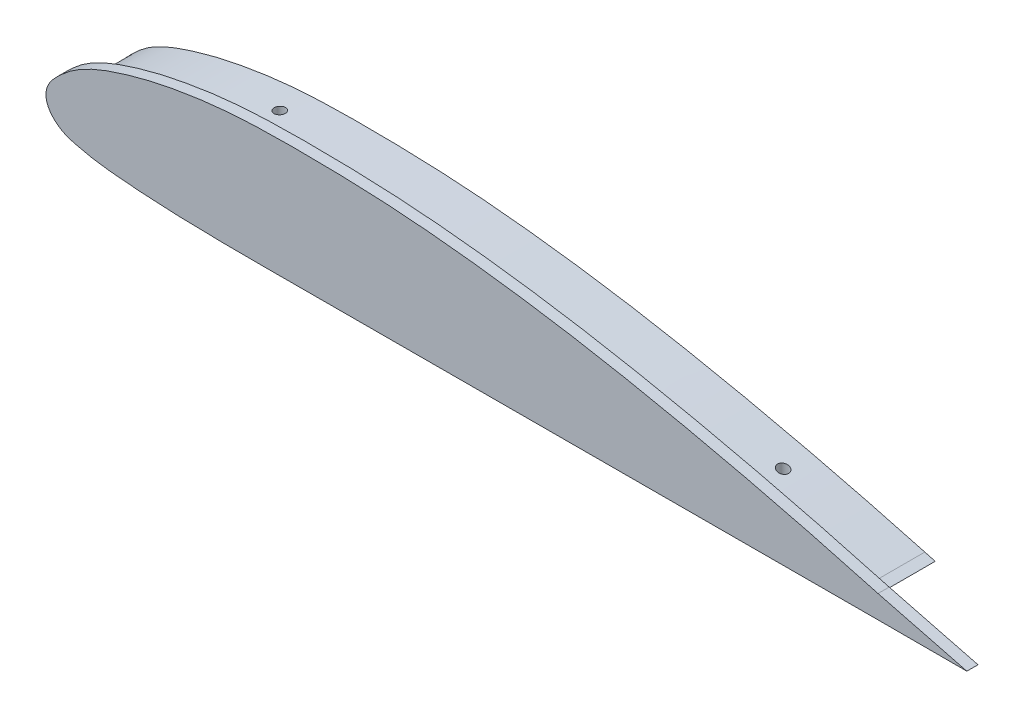
from build123d import *

# Parameters (mm, degrees)
BOSS_EXTRUDE1_DEPTH = 2
BOSS_EXTRUDE2_DEPTH = 10
SKETCH5_R           = 1
CUT_EXTRUDE1_DEPTH  = 36.779701738
CUT_EXTRUDE2_DEPTH  = 10


with BuildPart() as part:
    # Sketch1 → Boss-Extrude1 (new body)
    with BuildSketch(Plane.XY):
        with BuildLine():
            Line((-17.71228779, -35.575775075), (-1.223783329, -35.575775075))
            Line((-1.223783329, -35.575775075), (-17.180879623, -31.471027744))
            add(Edge.make_bspline(
                [(-17.180879623, -31.471027744), (-20.205601063, -30.641326221), (-26.253542154, -28.987884931), (-38.429053109, -25.8814615), (-53.732549887, -22.35224182), (-72.246941298, -18.747840877), (-87.841555491, -16.525613317), (-100.385741413, -15.297530048), (-109.848619286, -14.732094345), (-119.294599062, -14.543032016), (-127.178320958, -14.56973262), (-133.539223008, -14.903304234), (-138.316711816, -15.384960118), (-143.052256856, -16.102664967), (-146.974276822, -16.888033103), (-150.097568386, -17.661404713), (-152.420429022, -18.322368996), (-154.721034301, -19.055449549), (-157.028277155, -19.901839278), (-158.938274428, -20.750408796), (-160.444884569, -21.55195455), (-161.566657514, -22.242769671), (-162.643932605, -23.019791562), (-163.650195181, -23.881188916), (-164.383575737, -24.558119651), (-165.025928384, -25.197908158), (-165.520248718, -25.756694424), (-166.01404091, -26.440083904), (-166.389529061, -27.174457782), (-166.606560914, -27.962527196), (-166.659336808, -28.649852251), (-166.591247193, -29.291839365), (-166.3998375, -29.929741557), (-166.173442593, -30.404271636), (-165.821410784, -30.981688892), (-165.334747379, -31.561760653), (-164.720612919, -32.122103636), (-164.034637493, -32.61453888), (-163.289346674, -33.008452563), (-162.335975169, -33.387772412), (-161.22390742, -33.682088018), (-160.104439348, -33.942204217), (-158.883960635, -34.21330953), (-157.657113746, -34.434015389), (-156.022342218, -34.670136087), (-154.015300198, -34.873778442), (-151.668906344, -35.07398473), (-148.50365767, -35.312261934), (-144.559314611, -35.521168431), (-139.829186921, -35.675419619), (-135.108692198, -35.753722312), (-130.396839566, -35.782270868), (-125.692032249, -35.778984727), (-119.431159104, -35.756330318), (-111.611698629, -35.742482847), (-102.219561445, -35.729658954), (-92.83016126, -35.711302455), (-83.440388902, -35.694221978), (-70.920821592, -35.6710383), (-55.271517114, -35.643697918), (-36.492093713, -35.609371091), (-23.972198663, -35.587692749), (-17.71228779, -35.575775075)],
                knots=[0, 0, 0, 0, 0.03125, 0.0625, 0.125, 0.1875, 0.25, 0.28125, 0.3125, 0.34375, 0.375, 0.390625, 0.40625, 0.421875, 0.4375, 0.4453125, 0.453125, 0.4609375, 0.46875, 0.4765625, 0.48046875, 0.484375, 0.48828125, 0.4921875, 0.49609375, 0.498046875, 0.5, 0.501953125, 0.50390625, 0.504882812, 0.505859375, 0.506835938, 0.5078125, 0.508789062, 0.509765625, 0.51171875, 0.513671875, 0.515625, 0.517578125, 0.51953125, 0.5234375, 0.52734375, 0.53125, 0.53515625, 0.5390625, 0.546875, 0.5546875, 0.5625, 0.578125, 0.59375, 0.609375, 0.625, 0.640625, 0.65625, 0.6875, 0.71875, 0.75, 0.78125, 0.8125, 0.875, 0.9375, 1, 1, 1, 1], degree=3))
        make_face()
    extrude(amount=BOSS_EXTRUDE1_DEPTH)

    # Sketch4 → Boss-Extrude2 (add)
    with BuildSketch(Plane(origin=(0, 0, 0), x_dir=(-1, 0, 0), z_dir=(0, 0, -1))):
        with BuildLine():
            Line((17.70994939, -33.399779978), (17.7160954, -33.575778699))
            add(Edge.make_bspline(
                [(17.70994939, -33.399779978), (19.651879012, -32.867095565), (22.563577112, -32.068319692), (27.420043962, -30.770118295), (33.245486379, -29.263746739), (39.081710642, -27.826208531), (45.890157396, -26.226160187), (52.694169635, -24.702622889), (63.393948351, -22.501240747), (76.046850402, -20.202357345), (89.72564403, -18.331315967), (99.51568519, -17.393518183), (108.324863288, -16.817445171), (114.204364426, -16.625806752), (121.066356809, -16.561943444), (125.974053082, -16.571502562), (130.885253097, -16.744600599), (135.808351082, -17.114028774), (139.751938673, -17.602112713), (144.693017977, -18.44394121), (148.659981722, -19.315580588), (152.605023579, -20.461616952), (155.609352954, -21.476898751), (158.10574626, -22.546160182), (160.099824574, -23.655274475), (161.514645593, -24.657277192), (162.584438213, -25.617715585), (163.40244433, -26.391129499), (163.92459747, -26.95920193), (164.313902225, -27.510889309), (164.529063894, -27.94731657), (164.665704002, -28.464727875), (164.633170087, -28.89403193), (164.497358253, -29.271471481), (164.347818388, -29.573067596), (164.038218145, -30.0159236), (163.559116143, -30.490546425), (162.805207961, -31.040144352), (161.724262788, -31.501747246), (160.336321191, -31.832176674), (158.878451825, -32.175367079), (157.416123253, -32.451072602), (155.464334416, -32.72720523), (153.018038933, -32.95366966), (150.084495558, -33.195866586), (144.214110636, -33.568816871), (134.411361479, -33.820633073), (120.684790239, -33.752233713), (107.936738414, -33.739515262), (92.246192338, -33.710414817), (76.55564883, -33.681393812), (60.865096849, -33.652989659), (50.077844443, -33.63457102), (41.251915416, -33.617768164), (32.425981314, -33.602783128), (24.580710214, -33.587876536), (19.677413157, -33.579512674), (17.7160954, -33.575778699)],
                knots=[0, 0, 0, 0, 0.020105055, 0.030145261, 0.050190794, 0.080180377, 0.09015591, 0.120020101, 0.149793491, 0.199219015, 0.248395636, 0.287604023, 0.297393127, 0.336534715, 0.346322474, 0.365907652, 0.385530879, 0.395375762, 0.415192461, 0.425184025, 0.445412191, 0.455710779, 0.466190959, 0.477054504, 0.482786727, 0.488945835, 0.494316033, 0.497126416, 0.500187368, 0.502000869, 0.503849971, 0.505020137, 0.507317905, 0.507986558, 0.509023586, 0.510668219, 0.513358348, 0.515715812, 0.519949385, 0.524973188, 0.5299544, 0.534903202, 0.539824123, 0.549630394, 0.559425369, 0.569214167, 0.608355933, 0.657307127, 0.70626328, 0.735636871, 0.813966735, 0.862922864, 0.892296527, 0.921670208, 0.951043871, 0.980417552, 1, 1, 1, 1], degree=3))
        make_face()
    extrude(amount=BOSS_EXTRUDE2_DEPTH)

    # Sketch5 → Cut-Extrude1 (cut, through all)
    with BuildSketch(Plane(origin=(0, 0, 0), x_dir=(1, 0, 0), z_dir=(0, 1, 0))):
        with Locations((-131.639435551, 5)):
            Circle(SKETCH5_R)
        with Locations((-41.223783329, 5)):
            Circle(SKETCH5_R)
    extrude(amount=-CUT_EXTRUDE1_DEPTH, mode=Mode.SUBTRACT)

    # Sketch6 → Cut-Extrude2 (cut)
    with BuildSketch(Plane(origin=(0, 0, -10), x_dir=(-1, 0, 0), z_dir=(0, 0, -1))):
        with BuildLine():
            Line((1.223783329, -35.575775075), (17.71228779, -35.575775075))
            add(Edge.make_bspline(
                [(17.71228779, -35.575775075), (23.972198663, -35.587692749), (36.492093713, -35.609371091), (55.271517114, -35.643697918), (70.920821592, -35.6710383), (83.440388903, -35.694221978), (92.83016126, -35.711302455), (102.219561446, -35.729658954), (111.611698629, -35.742482847), (119.431159105, -35.756330318), (125.692032249, -35.778984727), (130.396839566, -35.782270868), (135.108692198, -35.753722312), (139.829186921, -35.675419619), (144.559314611, -35.521168431), (148.50365767, -35.312261934), (151.668906344, -35.07398473), (154.015300198, -34.873778442), (156.022342218, -34.670136087), (157.657113746, -34.434015389), (158.883960635, -34.21330953), (160.104439348, -33.942204217), (161.22390742, -33.682088018), (162.335975169, -33.387772412), (163.289346674, -33.008452563), (164.034637493, -32.61453888), (164.720612919, -32.122103636), (165.334747379, -31.561760653), (165.821410784, -30.981688892), (166.173442594, -30.404271636), (166.3998375, -29.929741557), (166.591247193, -29.291839365), (166.659336808, -28.649852251), (166.606560914, -27.962527196), (166.389529061, -27.174457782), (166.014040911, -26.440083904), (165.520248718, -25.756694424), (165.025928384, -25.197908158), (164.383575738, -24.558119651), (163.650195181, -23.881188916), (162.643932605, -23.019791562), (161.566657514, -22.242769671), (160.444884569, -21.55195455), (158.938274428, -20.750408796), (157.028277155, -19.901839278), (154.721034301, -19.055449549), (152.420429022, -18.322368996), (150.097568386, -17.661404713), (146.974276822, -16.888033103), (143.052256856, -16.102664967), (138.316711816, -15.384960118), (133.539223008, -14.903304234), (127.178320958, -14.56973262), (119.294599062, -14.543032016), (109.848619286, -14.732094345), (100.385741413, -15.297530048), (87.841555491, -16.525613317), (72.246941298, -18.747840877), (53.732549887, -22.35224182), (38.429053109, -25.8814615), (26.253542154, -28.987884931), (20.205601063, -30.641326221), (17.180879623, -31.471027744)],
                knots=[0, 0, 0, 0, 0.0625, 0.125, 0.1875, 0.21875, 0.25, 0.28125, 0.3125, 0.34375, 0.359375, 0.375, 0.390625, 0.40625, 0.421875, 0.4375, 0.4453125, 0.453125, 0.4609375, 0.46484375, 0.46875, 0.47265625, 0.4765625, 0.48046875, 0.482421875, 0.484375, 0.486328125, 0.48828125, 0.490234375, 0.491210938, 0.4921875, 0.493164062, 0.494140625, 0.495117188, 0.49609375, 0.498046875, 0.5, 0.501953125, 0.50390625, 0.5078125, 0.51171875, 0.515625, 0.51953125, 0.5234375, 0.53125, 0.5390625, 0.546875, 0.5546875, 0.5625, 0.578125, 0.59375, 0.609375, 0.625, 0.65625, 0.6875, 0.71875, 0.75, 0.8125, 0.875, 0.9375, 0.96875, 1, 1, 1, 1], degree=3))
            Line((17.180879623, -31.471027744), (1.223783329, -35.575775075))
        make_face()
        with BuildLine():
            Line((18.91256747, -33.328059638), (20.710392806, -33.33124838))
            add(Edge.make_bspline(
                [(20.710392806, -33.33124838), (26.84302725, -33.342125625), (39.108299632, -33.36428352), (57.506183233, -33.397352116), (75.904133448, -33.430231786), (91.235705772, -33.458112462), (103.500999254, -33.482061596), (112.699627982, -33.493268702), (121.899658594, -33.513545496), (129.564267264, -33.541622838), (135.693753844, -33.496544033), (140.289609178, -33.412858952), (144.881592412, -33.254362928), (148.704316905, -33.044512446), (151.756219842, -32.80859775), (154.046824319, -32.61204765), (156.324368552, -32.372076879), (158.201712675, -32.06347916), (159.68646139, -31.728604414), (160.808511278, -31.468412121), (161.894124206, -31.168523282), (162.894304694, -30.706258503), (163.741214987, -30.010229128), (164.393900683, -29.124006381), (164.420476186, -28.131546844), (163.822708418, -27.202192423), (163.053345641, -26.393620978), (162.210233196, -25.614745094), (161.353997269, -24.872451396), (160.13809842, -23.977052483), (158.498242625, -23.028887541), (156.420238055, -22.086160695), (154.278553211, -21.283459789), (151.37129613, -20.340952194), (147.68453464, -19.339282857), (143.189633108, -18.415026055), (138.656019956, -17.700915036), (134.094577233, -17.206092179), (127.985225236, -16.842138938), (120.325712678, -16.786374903), (111.133312691, -16.942174931), (101.956613994, -17.434183394), (92.803955496, -18.283579214), (83.67803365, -19.395522367), (71.557321977, -21.215898715), (56.498712626, -24.075735121), (38.5575052, -28.119238592), (26.689317811, -31.204352634), (20.77580884, -32.819238013)],
                knots=[0.010352061, 0.010352061, 0.010352061, 0.010352061, 0.071582315, 0.132812569, 0.194042822, 0.255273076, 0.285888203, 0.31650333, 0.347118457, 0.377733584, 0.393041148, 0.408348711, 0.423656275, 0.438963838, 0.44661762, 0.454271402, 0.461925183, 0.469578965, 0.473405856, 0.477232747, 0.481059638, 0.484886529, 0.48871342, 0.49254031, 0.496367201, 0.500194092, 0.504020983, 0.507847874, 0.511674765, 0.515501656, 0.523155437, 0.530809219, 0.538463001, 0.546116783, 0.561424346, 0.57673191, 0.592039473, 0.607347037, 0.6226546, 0.653269727, 0.683884854, 0.714499981, 0.745115108, 0.775730235, 0.806345362, 0.867575616, 0.92880587, 0.990036124, 0.990036124, 0.990036124, 0.990036124], degree=3))
            Line((20.77580884, -32.819238013), (18.91256747, -33.328059638))
        make_face(mode=Mode.SUBTRACT)
    extrude(amount=-CUT_EXTRUDE2_DEPTH, mode=Mode.SUBTRACT)


solid = part.part
